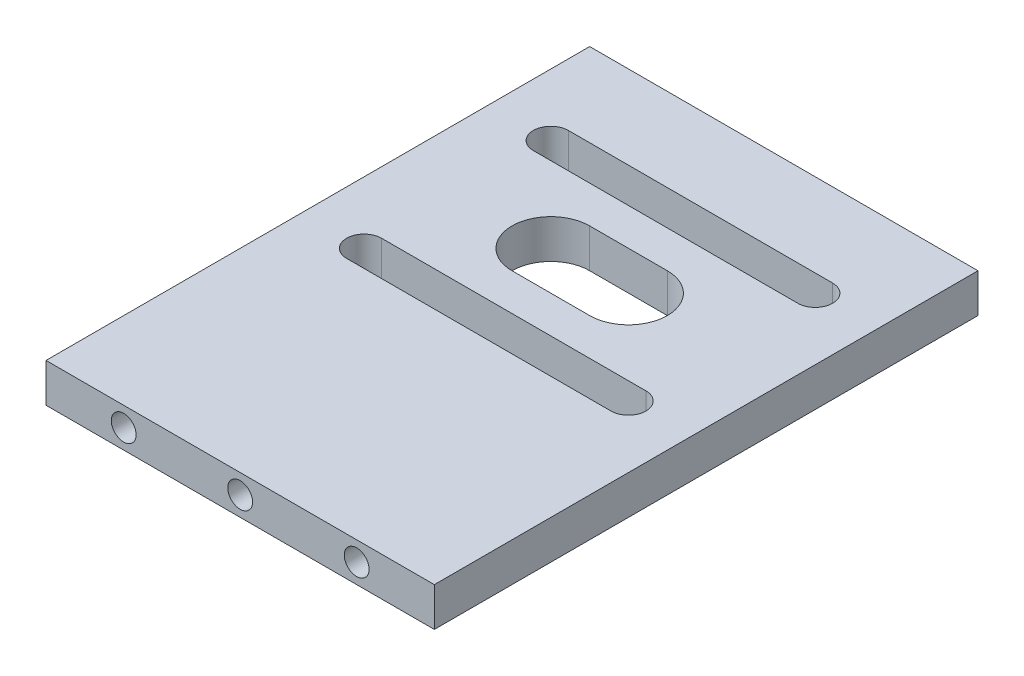
from build123d import *

# Parameters (mm, degrees)
SKETCH1_W           = 50
SKETCH1_H           = 70
BOSS_EXTRUDE1_DEPTH = 5
SKETCH2_R           = 1.6
CUT_EXTRUDE1_DEPTH  = 10


with BuildPart() as part:
    # Sketch1 → Boss-Extrude1 (new body)
    with BuildSketch(Plane(origin=(0, 0, 0), x_dir=(1, 0, 0), z_dir=(0, 1, 0))):
        with Locations((-9.575074469, 8.274395374)):
            Rectangle(SKETCH1_W, SKETCH1_H)
        with BuildLine():
            Line((-26.595889749, 32.545210655), (7.445740812, 32.545210655))
            ThreePointArc((7.445740812, 32.545210655), (9.695740812, 30.295210655), (7.445740812, 28.045210655))
            Line((7.445740812, 28.045210655), (-26.595889749, 28.045210655))
            ThreePointArc((-26.595889749, 28.045210655), (-28.845889749, 30.295210655), (-26.595889749, 32.545210655))
        make_face(mode=Mode.SUBTRACT)
        with BuildLine():
            Line((-14.575074469, 23.274395374), (-4.575074469, 23.274395374))
            ThreePointArc((-4.575074469, 23.274395374), (0.424925531, 18.274395374), (-4.575074469, 13.274395374))
            Line((-4.575074469, 13.274395374), (-14.575074469, 13.274395374))
            ThreePointArc((-14.575074469, 13.274395374), (-19.575074469, 18.274395374), (-14.575074469, 23.274395374))
        make_face(mode=Mode.SUBTRACT)
        with BuildLine():
            Line((-26.595889749, 4.003580094), (7.445740812, 4.003580094))
            ThreePointArc((7.445740812, 4.003580094), (9.695740812, 6.253580094), (7.445740812, 8.503580094))
            Line((7.445740812, 8.503580094), (-26.595889749, 8.503580094))
            ThreePointArc((-26.595889749, 8.503580094), (-28.845889749, 6.253580094), (-26.595889749, 4.003580094))
        make_face(mode=Mode.SUBTRACT)
    extrude(amount=BOSS_EXTRUDE1_DEPTH)

    # Sketch2 → Cut-Extrude1 (cut)
    with BuildSketch(Plane.XY.offset(26.725604626)):
        with Locations((-9.575074469, 2.5)):
            Circle(SKETCH2_R)
        with Locations((-24.575074469, 2.5)):
            Circle(SKETCH2_R)
        with Locations((5.424925531, 2.5)):
            Circle(SKETCH2_R)
    extrude(amount=-CUT_EXTRUDE1_DEPTH, mode=Mode.SUBTRACT)


solid = part.part
